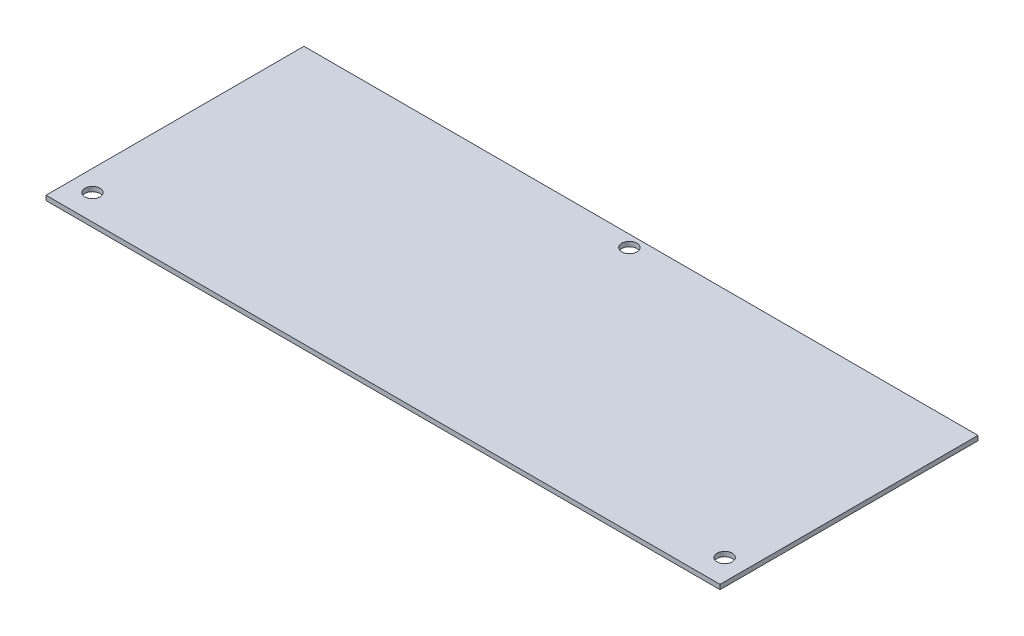
from build123d import *

# Parameters (mm, degrees)
SKETCH2_W           = 290
SKETCH2_H           = 111
SKETCH2_R           = 3.25
BOSS_EXTRUDE1_DEPTH = 2


with BuildPart() as part:
    # Sketch2 → Boss-Extrude1 (new body)
    with BuildSketch(Plane(origin=(0, 0, 0), x_dir=(1, 0, 0), z_dir=(0, 1, 0))):
        with Locations((-145, -55.5)):
            Rectangle(SKETCH2_W, SKETCH2_H)
        with Locations((-145, -5)):
            Circle(SKETCH2_R, mode=Mode.SUBTRACT)
        with Locations((-281, -100)):
            Circle(SKETCH2_R, mode=Mode.SUBTRACT)
        with Locations((-9, -100)):
            Circle(SKETCH2_R, mode=Mode.SUBTRACT)
    extrude(amount=BOSS_EXTRUDE1_DEPTH)


solid = part.part
